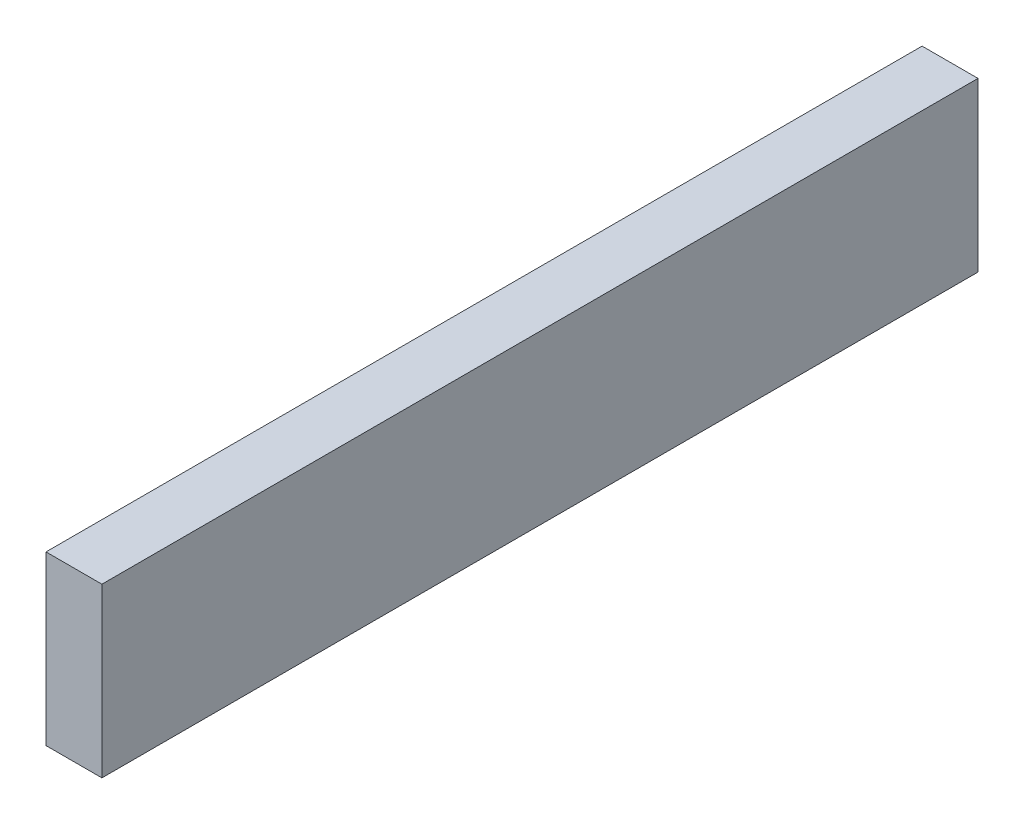
from build123d import *

# Parameters (mm, degrees)
SKETCH1_W           = 30
SKETCH1_H           = 90
BOSS_EXTRUDE1_DEPTH = 235


with BuildPart() as part:
    # Sketch1 → Boss-Extrude1 (new body, symmetric)
    with BuildSketch(Plane.XY):
        Rectangle(SKETCH1_W, SKETCH1_H)
    extrude(amount=BOSS_EXTRUDE1_DEPTH, both=True)


solid = part.part
